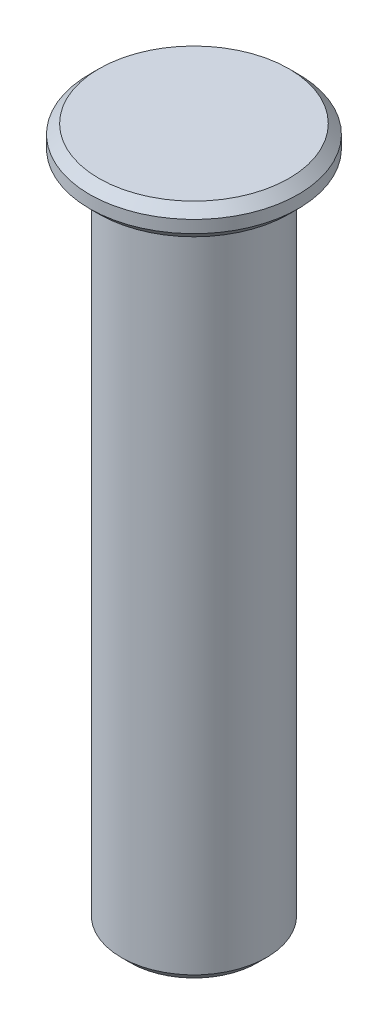
from build123d import *

# Parameters (mm, degrees)
SKETCH2_R           = 4.7
BOSS_EXTRUDE1_DEPTH = 45
SKETCH3_R           = 6.75
BOSS_EXTRUDE2_DEPTH = 2
CHAMFER1_SIZE       = 0.6


with BuildPart() as part:
    # Sketch2 → Boss-Extrude1 (new body)
    with BuildSketch(Plane(origin=(0, 0, 0), x_dir=(1, 0, 0), z_dir=(0, 1, 0))):
        Circle(SKETCH2_R)
    extrude(amount=BOSS_EXTRUDE1_DEPTH)

    # Sketch3 → Boss-Extrude2 (add)
    with BuildSketch(Plane(origin=(0, 45, 0), x_dir=(1, 0, 0), z_dir=(0, 1, 0))):
        Circle(SKETCH3_R)
    extrude(amount=-BOSS_EXTRUDE2_DEPTH)

    # Chamfer1
    chamfer1_edges = [part.edges().sort_by_distance(p)[0] for p in [
        (-4.7, 0, 0),
        (-6.75, 45, 0),
        (-6.75, 43, 0),
    ]]
    chamfer(chamfer1_edges, length=CHAMFER1_SIZE)


solid = part.part
